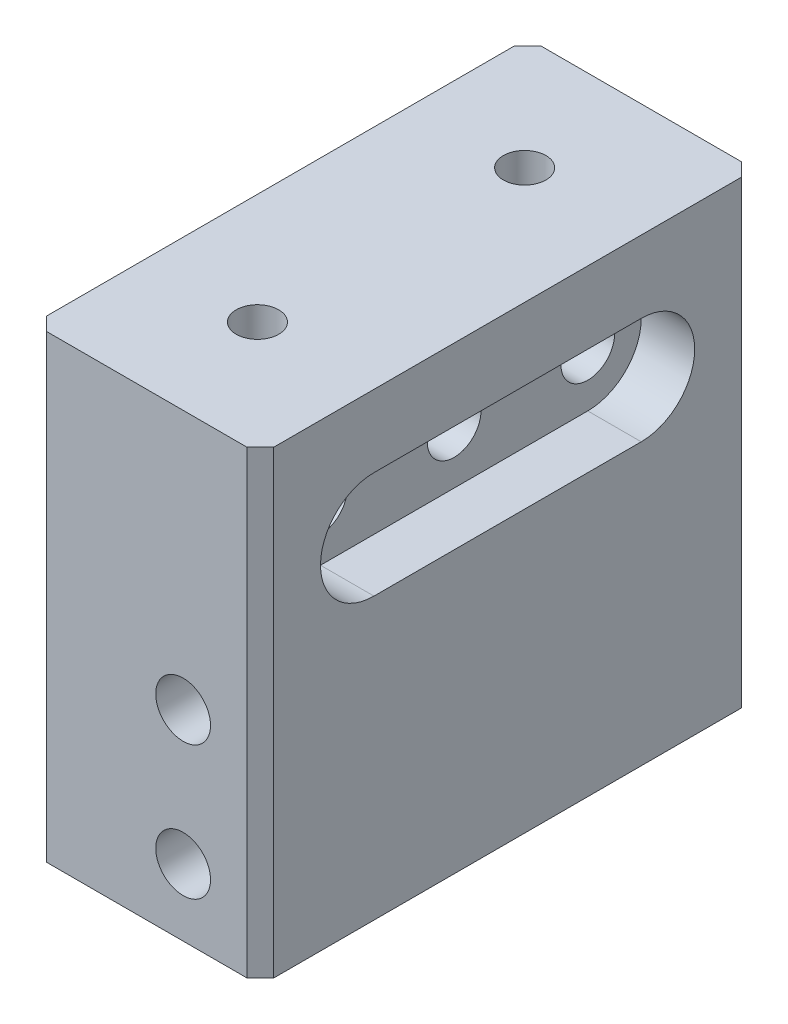
from build123d import *

# Parameters (mm, degrees)
SKETCH1_W           = 21.59
SKETCH1_H           = 46.99
BOSS_EXTRUDE1_DEPTH = 19.05
SKETCH2_R           = 2.6035
CUT_EXTRUDE1_DEPTH  = 47.99
SKETCH4_R           = 2.5527
CUT_EXTRUDE3_DEPTH  = 22.59
CUT_EXTRUDE5_DEPTH  = 5.08
SKETCH8_W           = 21.59
SKETCH8_H           = 46.99
BOSS_EXTRUDE2_DEPTH = 5.588
SKETCH9_R           = 2.0193
CUT_EXTRUDE6_DEPTH  = 5.08
CHAMFER1_SIZE       = 1.27


with BuildPart() as part:
    # Sketch1 → Boss-Extrude1 (new body, symmetric)
    with BuildSketch(Plane(origin=(0, 0, 0), x_dir=(1, 0, 0), z_dir=(0, 1, 0))):
        Rectangle(SKETCH1_W, SKETCH1_H)
    extrude(amount=BOSS_EXTRUDE1_DEPTH, both=True)

    # Sketch2 → Cut-Extrude1 (cut, through all)
    with BuildSketch(Plane.XY.offset(23.495)):
        with Locations((3.4544, -12.7)):
            Circle(SKETCH2_R)
        with Locations((3.4544, 0)):
            Circle(SKETCH2_R)
    extrude(amount=-CUT_EXTRUDE1_DEPTH, mode=Mode.SUBTRACT)

    # Sketch4 → Cut-Extrude3 (cut, through all)
    with BuildSketch(Plane(origin=(10.795, 0, 0), x_dir=(0, 0, -1), z_dir=(1, 0, 0))):
        with Locations((-12.7, 12.7)):
            Circle(SKETCH4_R)
        with Locations((12.7, 12.7)):
            Circle(SKETCH4_R)
        with Locations((0, 12.7)):
            Circle(SKETCH4_R)
    extrude(amount=-CUT_EXTRUDE3_DEPTH, mode=Mode.SUBTRACT)

    # Sketch7 → Cut-Extrude5 (cut)
    with BuildSketch(Plane(origin=(10.795, 0, 0), x_dir=(0, 0, -1), z_dir=(1, 0, 0))):
        with BuildLine():
            Line((-12.7, 17.78), (12.7, 17.78))
            ThreePointArc((12.7, 17.78), (17.78, 12.7), (12.7, 7.62))
            Line((12.7, 7.62), (-12.7, 7.62))
            ThreePointArc((-12.7, 7.62), (-17.78, 12.7), (-12.7, 17.78))
        make_face()
    extrude(amount=-CUT_EXTRUDE5_DEPTH, mode=Mode.SUBTRACT)

    # Sketch8 → Boss-Extrude2 (add)
    with BuildSketch(Plane(origin=(0, 19.05, 0), x_dir=(1, 0, 0), z_dir=(0, 1, 0))):
        Rectangle(SKETCH8_W, SKETCH8_H)
    extrude(amount=BOSS_EXTRUDE2_DEPTH)

    # Sketch9 → Cut-Extrude6 (cut)
    with BuildSketch(Plane(origin=(0, 24.638, 0), x_dir=(1, 0, 0), z_dir=(0, 1, 0))):
        with Locations((-0.2794, 12.696926228)):
            Circle(SKETCH9_R)
        with Locations((-0.2794, -12.696926228)):
            Circle(SKETCH9_R)
    extrude(amount=-CUT_EXTRUDE6_DEPTH, mode=Mode.SUBTRACT)

    # Chamfer1
    chamfer1_edges = [part.edges().sort_by_distance(p)[0] for p in [
        (10.795, 2.794, 23.495),
        (-10.795, 2.794, 23.495),
        (-10.795, 2.794, -23.495),
        (10.795, 2.794, -23.495),
    ]]
    chamfer(chamfer1_edges, length=CHAMFER1_SIZE)


solid = part.part
